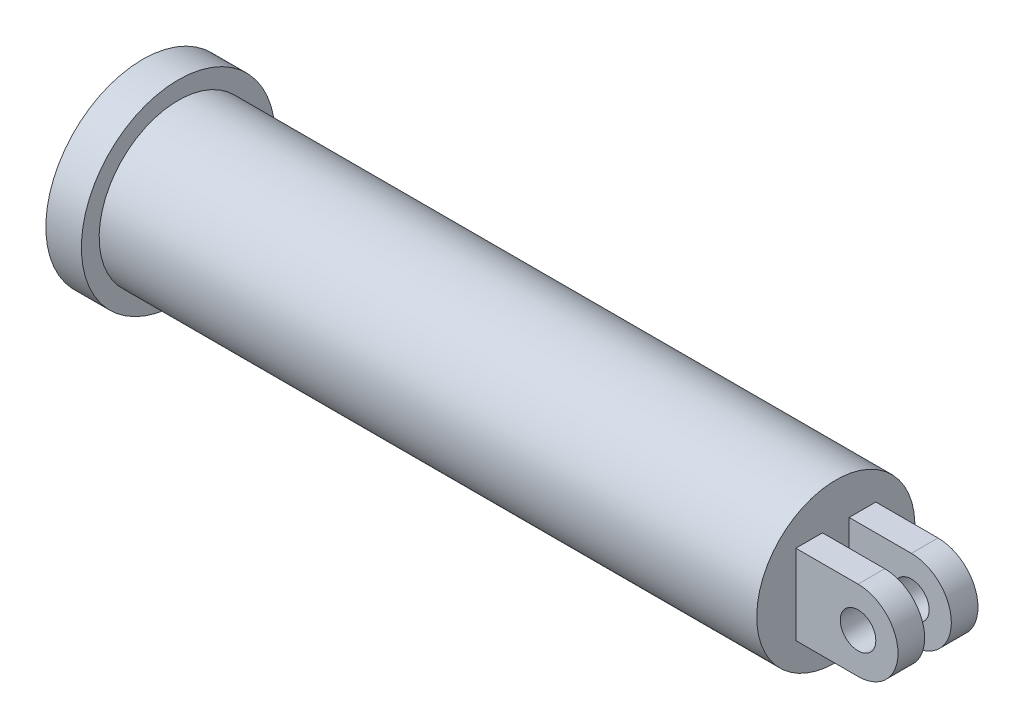
from build123d import *

# Parameters (mm, degrees)
SKETCH3_R           = 10
BOSS_EXTRUDE1_DEPTH = 15


with BuildPart() as part:
    # Sketch2 → Revolve1 (revolve)
    with BuildSketch(Plane.XY):
        Polygon((-195, 0), (195, 0), (195, 44.5), (-175, 44.5), (-175, 54.5), (-195, 54.5), align=None)
    revolve(axis=Axis((-195, 0, 0), (1, 0, 0)))

    # Sketch3 → Boss-Extrude1 (add)
    with BuildSketch(Plane.XY.offset(7.5)):
        with BuildLine():
            Line((195, 22.5), (230, 22.5))
            ThreePointArc((230, 22.5), (252.5, 0), (230, -22.5))
            Line((230, -22.5), (195, -22.5))
            Line((195, -22.5), (195, 22.5))
        make_face()
        with Locations((230, 0)):
            Circle(SKETCH3_R, mode=Mode.SUBTRACT)
    boss_extrude1 = extrude(amount=BOSS_EXTRUDE1_DEPTH)

    # Mirror1: Boss-Extrude1 across plane
    add(boss_extrude1.mirror(Plane.XY))


solid = part.part
